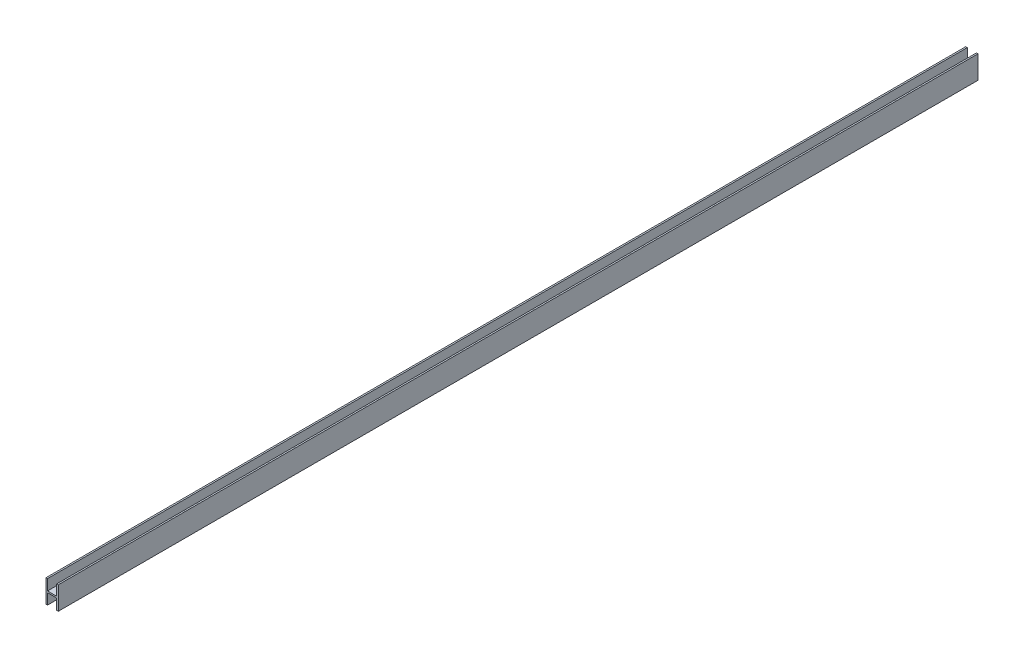
from build123d import *

# Parameters (mm, degrees)
SKETCH_1_W          = 8
SKETCH_1_H          = 15
EXTRUDE_1_DEPTH     = 600
SKETCH_2_W          = 6
SKETCH_2_H          = 14
CUT_EXTRUDE_1_DEPTH = 2400


with BuildPart() as part:
    # 草图1 → 凸台-拉伸1 (new body)
    with BuildSketch(Plane.XY):
        Rectangle(SKETCH_1_W, SKETCH_1_H)
    extrude(amount=EXTRUDE_1_DEPTH)

    # 草图2 → 切除-拉伸1 (cut)
    with BuildSketch(Plane(origin=(0, 0, 0), x_dir=(-1, 0, 0), z_dir=(0, 0, -1))):
        with Locations((0, -7.5)):
            Rectangle(SKETCH_2_W, SKETCH_2_H)
        with Locations((0, 7.5)):
            Rectangle(SKETCH_2_W, SKETCH_2_H)
    extrude(amount=-CUT_EXTRUDE_1_DEPTH, mode=Mode.SUBTRACT)


solid = part.part
